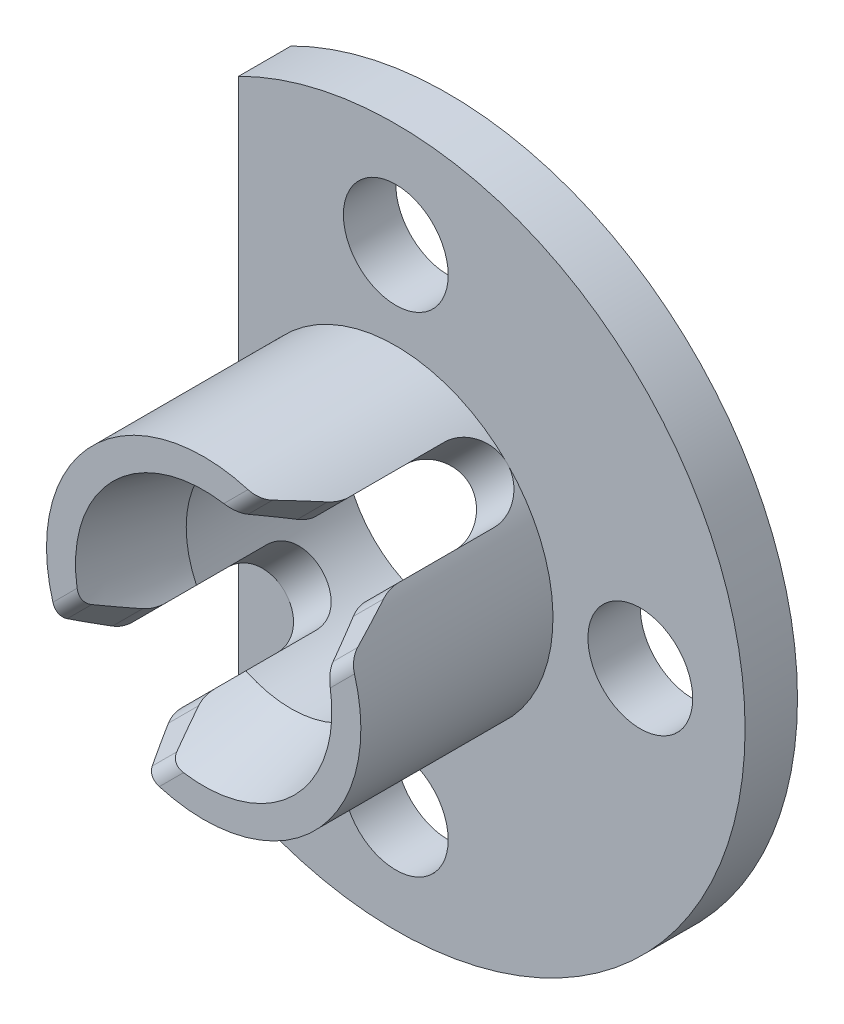
from build123d import *

# Parameters (mm, degrees)
ESQUISSE1_R                  = 3
BOSS_EXTRU_1_DEPTH           = 1.5
ENL_V_MAT_EXTRU_1_DEPTH      = 16.779733838
ENL_V_MAT_EXTRU_1_DEPTH_BACK = 16.779733838
ESQUISSE4_R                  = 1.5
ENL_V_MAT_EXTRU_2_DEPTH      = 14.2
CONG_2_R                     = 0.5


with BuildPart() as part:
    # Esquisse1 → Boss.-Extru.1 (new body)
    with BuildSketch(Plane.XY):
        with BuildLine():
            Line((-4.5, 8.93028555), (-4.5, -8.93028555))
            ThreePointArc((-4.5, -8.93028555), (5.029430583, -8.643195475), (9.987487585, -0.500091723))
            ThreePointArc((9.987487585, -0.500091723), (5.455376603, 8.380863089), (-4.5, 8.93028555))
        make_face()
        with Locations(Location((0, 0, 0), (0, 0, 180))):
            Circle(ESQUISSE1_R, mode=Mode.SUBTRACT)
    extrude(amount=BOSS_EXTRU_1_DEPTH)

    # Esquisse2 → R_volution1 (revolve)
    with BuildSketch(Plane(origin=(0, 0, 0), x_dir=(0, 0, -1), z_dir=(1, 0, 0)), mode=Mode.PRIVATE) as r_volution1_sk:
        Polygon((-1.5, 4.5), (-7, 4.5), (-7, 3.669872981), (-4.5, 3), (-1.5, 3), align=None)
    revolve(r_volution1_sk.sketch.rotate(Axis((0, 0, 0), (0, 0, 1)), 90), axis=Axis((0, 0, 0), (0, 0, 1)))

    # Esquisse3 → Enl_v. mat.-Extru.1 (cut, two sides)
    with BuildSketch(Plane(origin=(0, 0, 0), x_dir=(0, 0, 1), z_dir=(0.7071067811865464, 0.7071067811865488, 0))) as enl_v_mat_extru_1_sk:
        with BuildLine():
            Line((2.5, 1), (5.232050808, 1))
            ThreePointArc((5.232050808, 1), (5.490869853, 1.034074174), (5.732050808, 1.133974596))
            Line((5.732050808, 1.133974596), (7, 1.866025404))
            Line((7, 1.866025404), (7, -1.866025404))
            Line((7, -1.866025404), (5.732050808, -1.133974596))
            ThreePointArc((5.732050808, -1.133974596), (5.490869853, -1.034074174), (5.232050808, -1))
            Line((5.232050808, -1), (2.5, -1))
            ThreePointArc((2.5, -1), (1.5, 0), (2.5, 1))
        make_face()
    extrude(amount=ENL_V_MAT_EXTRU_1_DEPTH, mode=Mode.SUBTRACT)
    extrude(enl_v_mat_extru_1_sk.sketch, amount=-ENL_V_MAT_EXTRU_1_DEPTH_BACK, mode=Mode.SUBTRACT)

    # Esquisse4 → Enl_v. mat.-Extru.2 (cut)
    with BuildSketch(Plane.XY.offset(1.5)):
        with Locations((0, -7)):
            Circle(ESQUISSE4_R)
        with Locations((0, 7)):
            Circle(ESQUISSE4_R)
        with Locations((7, 0)):
            Circle(ESQUISSE4_R)
    extrude(amount=-ENL_V_MAT_EXTRU_2_DEPTH, mode=Mode.SUBTRACT)

    # Cong_2
    cong_2_edges = [part.edges().sort_by_distance(p)[0] for p in [
        (-3.884480351, -1.245521917, 7),
        (1.245521917, 3.884480351, 7),
        (3.884480351, 1.245521917, 7),
        (-1.245521917, -3.884480351, 7),
    ]]
    fillet(cong_2_edges, radius=CONG_2_R)


solid = part.part
